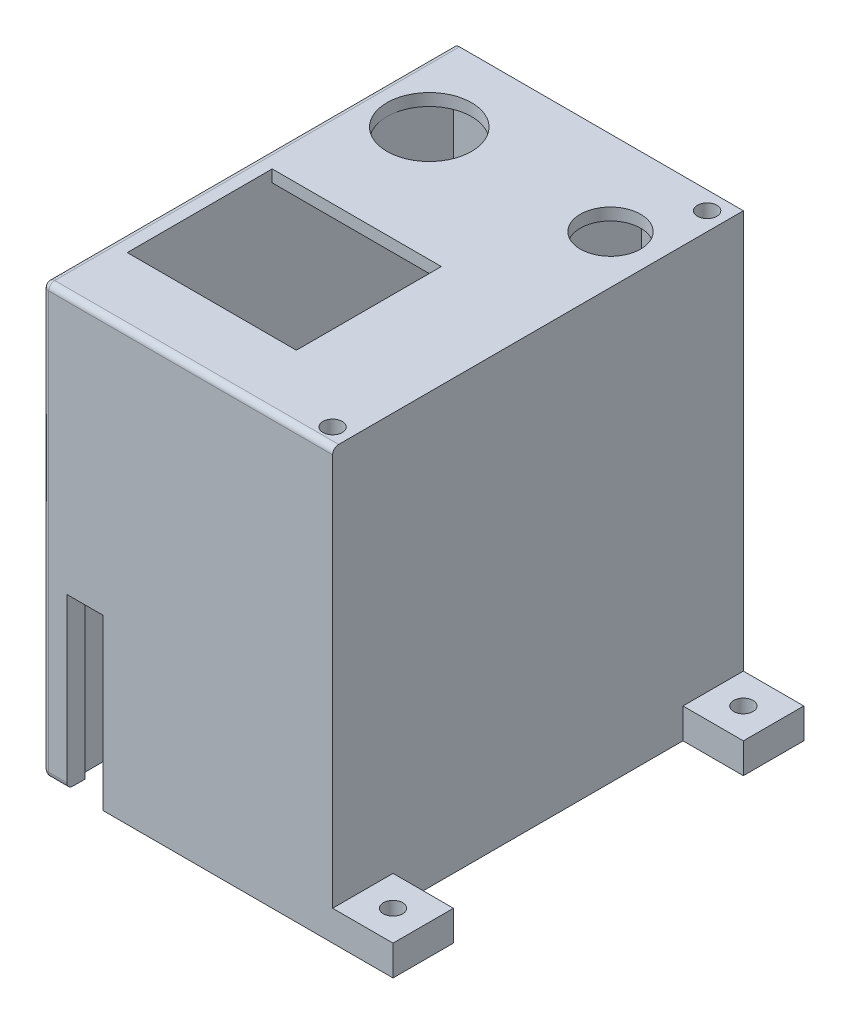
from build123d import *

# Parameters (mm, degrees)
SKETCH1_W           = 48
SKETCH1_H           = 68
BOSS_EXTRUDE1_DEPTH = 71
SKETCH2_W           = 42
SKETCH2_H           = 62
CUT_EXTRUDE1_DEPTH  = 69
SKETCH3_R           = 7
SKETCH3_R_2         = 5
SKETCH3_W           = 28
SKETCH3_H           = 24
CUT_EXTRUDE2_DEPTH  = 3
SKETCH4_W           = 6
SKETCH4_H           = 42
CUT_EXTRUDE3_DEPTH  = 3
SKETCH5_W           = 6
SKETCH5_H           = 28
CUT_EXTRUDE4_DEPTH  = 3
SKETCH6_W           = 3
SKETCH6_H           = 62
BOSS_EXTRUDE2_DEPTH = 69
SKETCH7_R           = 1.5
CUT_EXTRUDE5_DEPTH  = 3
SKETCH11_R          = 1.6
BOSS_EXTRUDE3_DEPTH = 71
SKETCH12_R          = 1.6
CUT_EXTRUDE6_DEPTH  = 71
BOSS_EXTRUDE4_DEPTH = 71
SKETCH14_R          = 1.6
CUT_EXTRUDE7_DEPTH  = 71
FILLET2_R           = 1
FILLET3_R           = 1
FILLET5_R           = 1
SKETCH17_W          = 10
SKETCH17_H          = 5
BOSS_EXTRUDE5_DEPTH = 10
SKETCH18_R          = 1.6
CUT_EXTRUDE8_DEPTH  = 5
SKETCH19_W          = 10
SKETCH19_H          = 5
BOSS_EXTRUDE6_DEPTH = 10
SKETCH20_R          = 1.6
CUT_EXTRUDE10_DEPTH = 5


with BuildPart() as part:
    # Sketch1 → Boss-Extrude1 (new body)
    with BuildSketch(Plane(origin=(0, 0, 0), x_dir=(1, 0, 0), z_dir=(0, 1, 0))):
        with Locations((0.690647482, -20.618705036)):
            Rectangle(SKETCH1_W, SKETCH1_H)
    extrude(amount=BOSS_EXTRUDE1_DEPTH)

    # Sketch2 → Cut-Extrude1 (cut)
    with BuildSketch(Plane.XZ):
        with Locations((0.690647482, 20.618705036)):
            Rectangle(SKETCH2_W, SKETCH2_H)
    extrude(amount=-CUT_EXTRUDE1_DEPTH, mode=Mode.SUBTRACT)

    # Sketch3 → Cut-Extrude2 (cut)
    with BuildSketch(Plane(origin=(0, 71, 0), x_dir=(1, 0, 0), z_dir=(0, 1, 0))):
        with Locations((-13.309352518, -0.618705036)):
            Circle(SKETCH3_R)
        with Locations((16.690647482, -0.618705036)):
            Circle(SKETCH3_R_2)
        with Locations((-6.309352518, -31.618705036)):
            Rectangle(SKETCH3_W, SKETCH3_H)
    extrude(amount=-CUT_EXTRUDE2_DEPTH, mode=Mode.SUBTRACT)

    # Sketch4 → Cut-Extrude3 (cut)
    with BuildSketch(Plane(origin=(0, 0, -13.381294964), x_dir=(-1, 0, 0), z_dir=(0, 0, -1))):
        with Locations((16.309352518, 21)):
            Rectangle(SKETCH4_W, SKETCH4_H)
    extrude(amount=-CUT_EXTRUDE3_DEPTH, mode=Mode.SUBTRACT)

    # Sketch5 → Cut-Extrude4 (cut)
    with BuildSketch(Plane.XY.offset(54.618705036)):
        with Locations((-16.309352518, 14)):
            Rectangle(SKETCH5_W, SKETCH5_H)
    extrude(amount=-CUT_EXTRUDE4_DEPTH, mode=Mode.SUBTRACT)

    # Sketch6 → Boss-Extrude2 (add)
    with BuildSketch(Plane.XZ.offset(-69)):
        with Locations((9.33286699, 20.618705036)):
            Rectangle(SKETCH6_W, SKETCH6_H)
    extrude(amount=BOSS_EXTRUDE2_DEPTH)

    # Sketch7 → Cut-Extrude5 (cut)
    with BuildSketch(Plane.ZY.offset(23.309352518)):
        with Locations((47.618705036, 63)):
            Circle(SKETCH7_R)
    extrude(amount=-CUT_EXTRUDE5_DEPTH, mode=Mode.SUBTRACT)

    # Sketch11 → Boss-Extrude3 (add)
    with BuildSketch(Plane(origin=(0, 71, 0), x_dir=(1, 0, 0), z_dir=(0, 1, 0))):
        with BuildLine():
            Line((19.044896171, 13.381294964), (24.690647482, 13.381294964))
            Line((24.690647482, 13.381294964), (24.690647482, 7.735543653))
            ThreePointArc((24.690647482, 7.735543653), (18.862220357, 7.552867839), (19.044896171, 13.381294964))
        make_face()
        with Locations((21.690647482, 10.381294964)):
            Circle(SKETCH11_R, mode=Mode.SUBTRACT)
    extrude(amount=-BOSS_EXTRUDE3_DEPTH)

    # Sketch12 → Cut-Extrude6 (cut)
    with BuildSketch(Plane(origin=(0, 71, 0), x_dir=(1, 0, 0), z_dir=(0, 1, 0))):
        with Locations((21.690647482, 10.381294964)):
            Circle(SKETCH12_R)
    extrude(amount=-CUT_EXTRUDE6_DEPTH, mode=Mode.SUBTRACT)

    # Sketch13 → Boss-Extrude4 (add)
    with BuildSketch(Plane(origin=(0, 71, 0), x_dir=(1, 0, 0), z_dir=(0, 1, 0))):
        with BuildLine():
            Line((19.044896171, -54.618705036), (24.690647482, -54.618705036))
            Line((24.690647482, -54.618705036), (24.690647482, -48.972953725))
            ThreePointArc((24.690647482, -48.972953725), (18.862220357, -48.790277911), (19.044896171, -54.618705036))
        make_face()
    extrude(amount=-BOSS_EXTRUDE4_DEPTH)

    # Sketch14 → Cut-Extrude7 (cut)
    with BuildSketch(Plane(origin=(0, 71, 0), x_dir=(1, 0, 0), z_dir=(0, 1, 0))):
        with Locations((21.690647482, -51.618705036)):
            Circle(SKETCH14_R)
    extrude(amount=-CUT_EXTRUDE7_DEPTH, mode=Mode.SUBTRACT)

    # Fillet2
    fillet2_edges = [part.edges().sort_by_distance(p)[0] for p in [
        (0.690647482, 71, 54.618705036),
    ]]
    fillet(fillet2_edges, radius=FILLET2_R)

    # Fillet3
    fillet3_edges = [part.edges().sort_by_distance(p)[0] for p in [
        (-23.309352518, 35, 54.618705036),
        (-23.309352518, 70.707106781, 54.325811817),
        (-23.309352518, 71, 20.118705036),
    ]]
    fillet(fillet3_edges, radius=FILLET3_R)

    # Fillet5
    fillet5_edges = [part.edges().sort_by_distance(p)[0] for p in [
        (-20.809352518, 0, 54.618705036),
        (-23.016459299, 0, 54.325811817),
        (-23.309352518, 0, 20.118705036),
    ]]
    fillet(fillet5_edges, radius=FILLET5_R)

    # Sketch17 → Boss-Extrude5 (add)
    with BuildSketch(Plane(origin=(24.690647482, 0, 0), x_dir=(0, 0, -1), z_dir=(1, 0, 0))):
        with Locations((-49.618705036, 2.5)):
            Rectangle(SKETCH17_W, SKETCH17_H)
    extrude(amount=BOSS_EXTRUDE5_DEPTH)

    # Sketch18 → Cut-Extrude8 (cut)
    with BuildSketch(Plane(origin=(0, 5, 0), x_dir=(1, 0, 0), z_dir=(0, 1, 0))):
        with Locations((29.690647482, -49.618705036)):
            Circle(SKETCH18_R)
    extrude(amount=-CUT_EXTRUDE8_DEPTH, mode=Mode.SUBTRACT)

    # Sketch19 → Boss-Extrude6 (add)
    with BuildSketch(Plane(origin=(24.690647482, 0, 0), x_dir=(0, 0, -1), z_dir=(1, 0, 0))):
        with Locations((8.381294964, 2.5)):
            Rectangle(SKETCH19_W, SKETCH19_H)
    extrude(amount=BOSS_EXTRUDE6_DEPTH)

    # Sketch20 → Cut-Extrude10 (cut)
    with BuildSketch(Plane(origin=(0, 5, 0), x_dir=(1, 0, 0), z_dir=(0, 1, 0))):
        with Locations((29.690647482, 8.381294964)):
            Circle(SKETCH20_R)
    extrude(amount=-CUT_EXTRUDE10_DEPTH, mode=Mode.SUBTRACT)


solid = part.part
